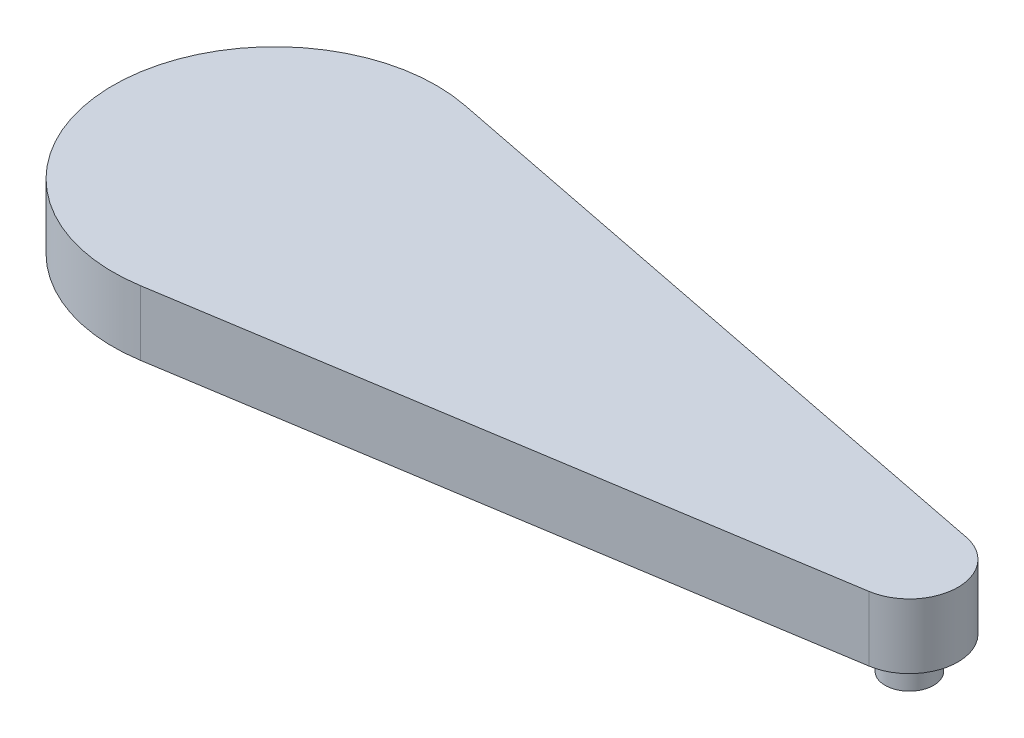
from build123d import *

# Parameters (mm, degrees)
BOSS_EXTRUDE1_DEPTH = 10
SKETCH3_R           = 3.75
CUT_EXTRUDE1_DEPTH  = 5
SKETCH4_R           = 3.75
BOSS_EXTRUDE2_DEPTH = 10


with BuildPart() as part:
    # Sketch1 → Boss-Extrude1 (new body)
    with BuildSketch(Plane(origin=(0, 0, 0), x_dir=(1, 0, 0), z_dir=(0, 1, 0))):
        with BuildLine():
            Line((101.452048182, 5.461568526), (4.840160607, 24.526981985))
            ThreePointArc((4.840160607, 24.526981985), (-24.995505199, 0.474046272), (3.906693314, -24.69286835))
            Line((3.906693314, -24.69286835), (101.172007994, -9.304386575))
            ThreePointArc((101.172007994, -9.304386575), (107.49865156, -2.038739951), (101.452048182, 5.461568526))
        make_face()
    extrude(amount=BOSS_EXTRUDE1_DEPTH)

    # Sketch3 → Cut-Extrude1 (cut)
    with BuildSketch(Plane.XZ):
        with Locations((100, 1.89652607)):
            Circle(SKETCH3_R)
        with BuildLine():
            Line((17.529407273, -2.952918523), (1.075988404, -5.902732327))
            ThreePointArc((1.075988404, -5.902732327), (-9e-09, -6), (-1.075988422, -5.902732329))
            Line((-1.075988422, -5.902732329), (-17.529407298, -2.952918565))
            ThreePointArc((-17.529407298, -2.952918565), (-20.000000128, 0), (-17.529407298, 2.952918565))
            Line((-17.529407298, 2.952918565), (-1.075988422, 5.902732329))
            ThreePointArc((-1.075988422, 5.902732329), (-9e-09, 6), (1.075988404, 5.902732327))
            Line((1.075988404, 5.902732327), (17.529407273, 2.952918523))
            ThreePointArc((17.529407273, 2.952918523), (19.999999872, 0), (17.529407273, -2.952918523))
        make_face()
    extrude(amount=-CUT_EXTRUDE1_DEPTH, mode=Mode.SUBTRACT)

    # Sketch4 → Boss-Extrude2 (add)
    with BuildSketch(Plane.XZ.offset(-5)):
        with Locations((100, 1.89652607)):
            Circle(SKETCH4_R)
    extrude(amount=BOSS_EXTRUDE2_DEPTH)


solid = part.part
